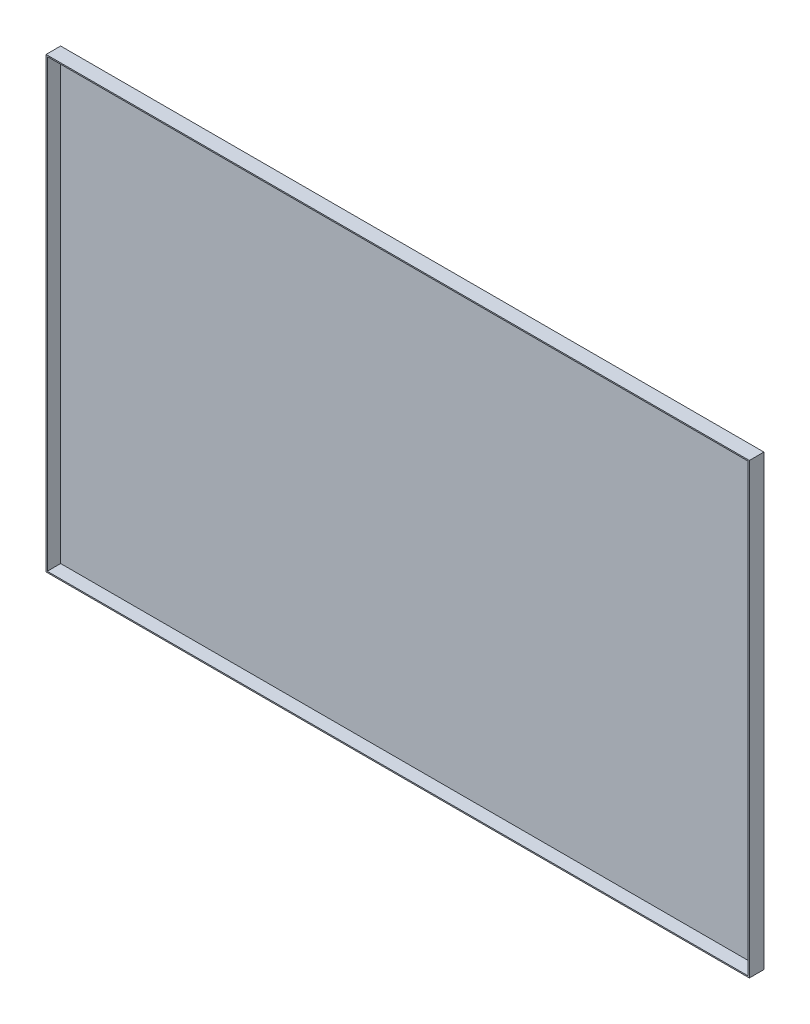
from build123d import *

# Parameters (mm, degrees)
SKETCH_1_W      = 579
SKETCH_1_H      = 369
EXTRUDE_1_DEPTH = 12
SHELL_1_T       = -1


with BuildPart() as part:
    # 草图1 → 凸台-拉伸1 (new body)
    with BuildSketch(Plane.XY):
        Rectangle(SKETCH_1_W, SKETCH_1_H)
    extrude(amount=EXTRUDE_1_DEPTH)

    # 抽壳1
    shell_1_openings = [part.faces().sort_by_distance(p)[0] for p in [
        (0, 0, 12),
    ]]
    offset(amount=SHELL_1_T, openings=shell_1_openings, kind=Kind.INTERSECTION)


solid = part.part
